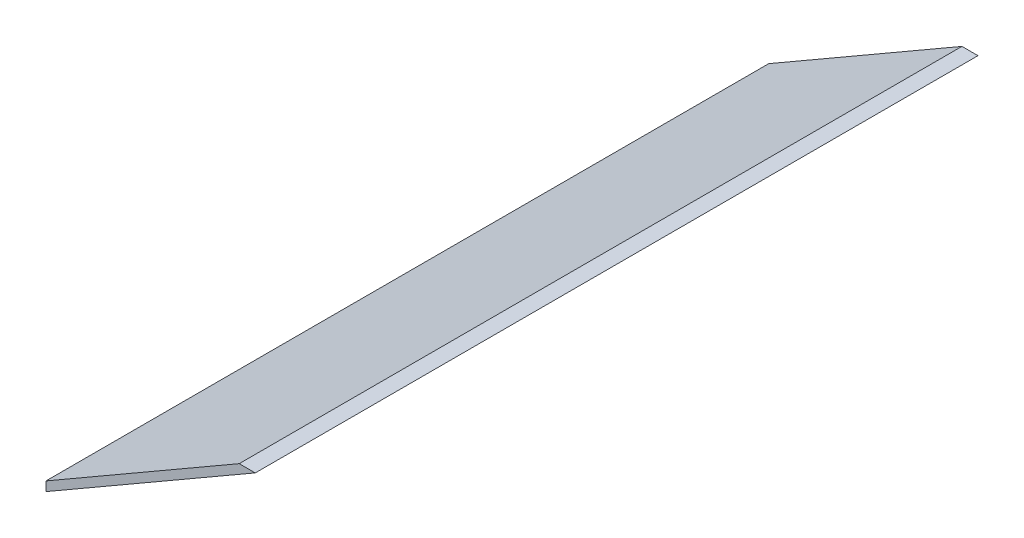
from build123d import *

# Parameters (mm, degrees)
AUFSATZ_LINEAR_AUSTRAGEN1_DEPTH = 450


with BuildPart() as part:
    # Skizze1 → Aufsatz-Linear austragen1 (new body)
    with BuildSketch(Plane.XY):
        Polygon((227.804485184, 257.731329598), (217.804485184, 257.731329598), (97.5, 188.273502692), (97.5, 182.5), align=None)
    extrude(amount=AUFSATZ_LINEAR_AUSTRAGEN1_DEPTH)


solid = part.part
